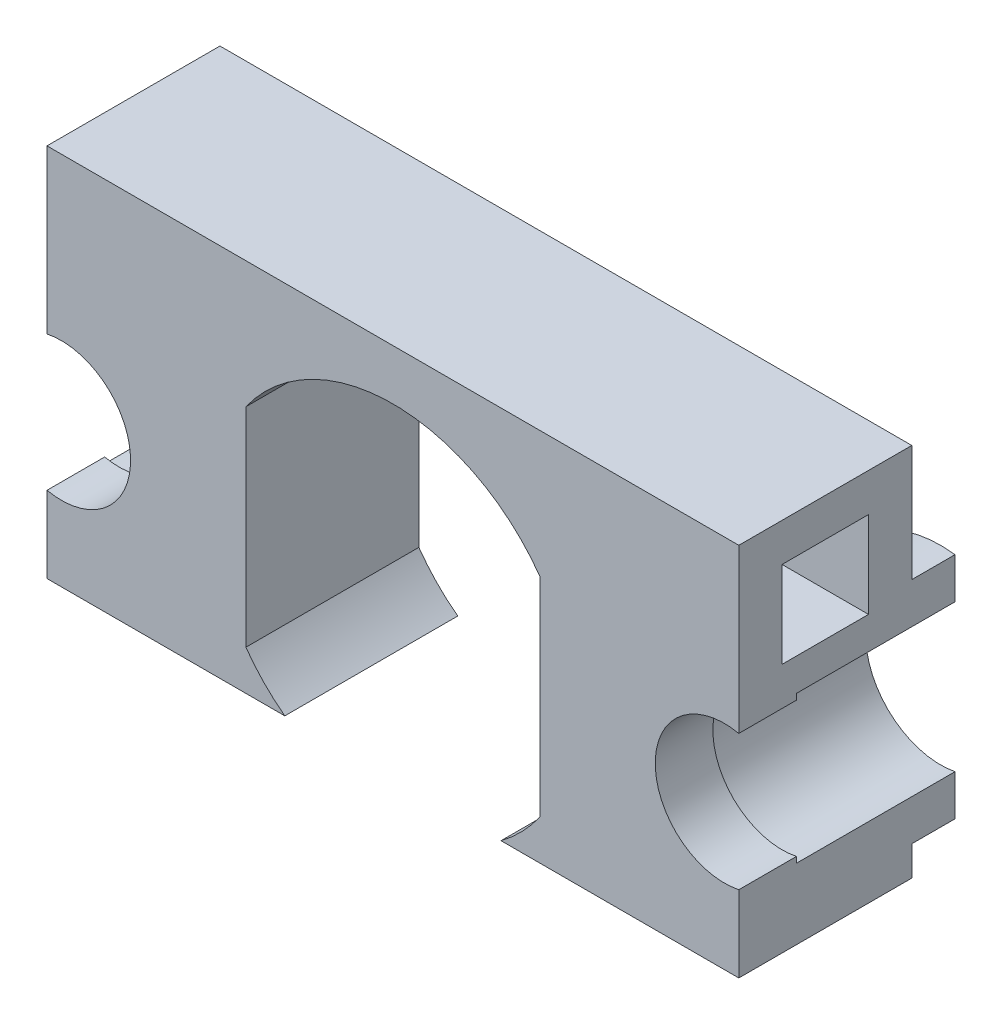
from build123d import *

# Parameters (mm, degrees)
SKETCH1_R            = 1
BOSS_EXTRUDE1_DEPTH  = 6
SKETCH2_R            = 2.6
CUT_EXTRUDE1_DEPTH   = 6
SKETCH3_W            = 7.6
SKETCH3_H            = 13
BOSS_EXTRUDE2_DEPTH  = 6
BOSS_EXTRUDE5_START  = -5
SKETCH6_W            = 3
SKETCH6_H            = 2
BOSS_EXTRUDE5_DEPTH  = 13
BOSS_EXTRUDE6_START  = -6
SKETCH10_R           = 4
SKETCH10_R_2         = 2.6
BOSS_EXTRUDE6_DEPTH  = 1.5
BOSS_EXTRUDE7_START  = -6
SKETCH12_R           = 2.6
SKETCH12_R_2         = 2.4
BOSS_EXTRUDE7_DEPTH  = 2
CUT_EXTRUDE2_DEPTH   = 7
SKETCH14_W           = 3
SKETCH14_H           = 6
CUT_EXTRUDE3_DEPTH   = 2
SKETCH15_W           = 0.2
SKETCH15_H           = 13
CUT_EXTRUDE5_DEPTH   = 7.5
SKETCH16_W           = 3
SKETCH16_H           = 3
CUT_EXTRUDE6_DEPTH   = 3
SKETCH17_W           = 2.8
SKETCH17_H           = 2.8
BOSS_EXTRUDE9_DEPTH  = 3
BOSS_EXTRUDE10_START = 24.4
SKETCH17_2_W         = 2.8
SKETCH17_2_H         = 2.8
BOSS_EXTRUDE10_DEPTH = 3
SKETCH18_W           = 5.7
SKETCH18_H           = 13
SKETCH18_W_2         = 13.3
CUT_EXTRUDE7_DEPTH   = 9
SKETCH19_W           = 3
SKETCH19_H           = 3
CUT_EXTRUDE8_DEPTH   = 3
CUT_EXTRUDE10_START  = -24
SKETCH19_3_W         = 3
SKETCH19_3_H         = 3
CUT_EXTRUDE10_DEPTH  = 3


with BuildPart() as part:
    # Sketch1 → Boss-Extrude1 (new body)
    with BuildSketch(Plane.XY):
        with BuildLine():
            ThreePointArc((3.75, -5), (4.47902769, -4.358991965), (5.1, -3.61282438))
            Line((5.1, -3.61282438), (5.1, 3.61282438))
            ThreePointArc((5.1, 3.61282438), (0, 6.25), (-5.1, 3.61282438))
            Line((-5.1, 3.61282438), (-5.1, -3.61282438))
            ThreePointArc((-5.1, -3.61282438), (-4.47902769, -4.358991965), (-3.75, -5))
            Line((-3.75, -5), (-14.7, -5))
            Line((-14.7, -5), (-14.7, 8))
            Line((-14.7, 8), (14.7, 8))
            Line((14.7, 8), (14.7, -5))
            Line((14.7, -5), (3.75, -5))
        make_face()
        with Locations((11.5, 0)):
            Circle(SKETCH1_R, mode=Mode.SUBTRACT)
        with Locations((-11.5, 0)):
            Circle(SKETCH1_R, mode=Mode.SUBTRACT)
    extrude(amount=BOSS_EXTRUDE1_DEPTH)

    # Sketch2 → Cut-Extrude1 (cut)
    with BuildSketch(Plane.XY):
        with Locations((-11.5, 0)):
            Circle(SKETCH2_R)
        with Locations((11.5, 0)):
            Circle(SKETCH2_R)
    extrude(amount=CUT_EXTRUDE1_DEPTH, mode=Mode.SUBTRACT)

    # Sketch3 → Boss-Extrude2 (add)
    with BuildSketch(Plane.XY):
        with Locations((-18.5, 1.5)):
            Rectangle(SKETCH3_W, SKETCH3_H)
    extrude(amount=BOSS_EXTRUDE2_DEPTH)

    # Sketch6 → Boss-Extrude5 (add)
    with BuildSketch(Plane(origin=(0, 0, 0), x_dir=(1, 0, 0), z_dir=(0, 1, 0)).offset(BOSS_EXTRUDE5_START)):
        with Locations((-23.8, -3)):
            Rectangle(SKETCH6_W, SKETCH6_H)
        with Locations((16.2, -3)):
            Rectangle(SKETCH6_W, SKETCH6_H)
    extrude(amount=BOSS_EXTRUDE5_DEPTH)

    # Sketch10 → Boss-Extrude6 (add)
    with BuildSketch(Plane.XY.offset(6).offset(BOSS_EXTRUDE6_START)):
        with Locations((-11.5, 0)):
            Circle(SKETCH10_R)
        with Locations((-11.5, 0)):
            Circle(SKETCH10_R_2, mode=Mode.SUBTRACT)
        with BuildLine():
            Line((14.7, 2.4), (14.7, -2.4))
            ThreePointArc((14.7, -2.4), (7.5, 0), (14.7, 2.4))
        make_face()
        with Locations((11.5, 0)):
            Circle(SKETCH10_R_2, mode=Mode.SUBTRACT)
    extrude(amount=-BOSS_EXTRUDE6_DEPTH)

    # Sketch12 → Boss-Extrude7 (add)
    with BuildSketch(Plane(origin=(0, 0, 0), x_dir=(-1, 0, 0), z_dir=(0, 0, -1)).offset(BOSS_EXTRUDE7_START)):
        with Locations((11.5, 0)):
            Circle(SKETCH12_R)
        with Locations((11.5, 0)):
            Circle(SKETCH12_R_2, mode=Mode.SUBTRACT)
        with Locations((-11.5, 0)):
            Circle(SKETCH12_R)
        with Locations((-11.5, 0)):
            Circle(SKETCH12_R_2, mode=Mode.SUBTRACT)
    extrude(amount=BOSS_EXTRUDE7_DEPTH)

    # Sketch13 → Cut-Extrude2 (cut)
    with BuildSketch(Plane.XZ.offset(5)):
        Polygon((-22.3, 0), (-16.3, 0), (-16.3, 2), (-17.8, 2), (-17.8, 6), (-20.8, 6), (-20.8, 2), (-22.3, 2), align=None)
    extrude(amount=-CUT_EXTRUDE2_DEPTH, mode=Mode.SUBTRACT)

    # Sketch14 → Cut-Extrude3 (cut)
    with BuildSketch(Plane(origin=(0, 0, 0), x_dir=(-1, 0, 0), z_dir=(0, 0, -1))):
        with Locations((19.3, 5)):
            Rectangle(SKETCH14_W, SKETCH14_H)
    extrude(amount=-CUT_EXTRUDE3_DEPTH, mode=Mode.SUBTRACT)

    # Sketch15 → Cut-Extrude5 (cut, symmetric)
    with BuildSketch(Plane.XY):
        with Locations((-12.1, 1.5)):
            Rectangle(SKETCH15_W, SKETCH15_H)
        with Locations((12.1, 1.5)):
            Rectangle(SKETCH15_W, SKETCH15_H)
    extrude(amount=CUT_EXTRUDE5_DEPTH, both=True, mode=Mode.SUBTRACT)

    # Sketch16 → Cut-Extrude6 (cut)
    with BuildSketch(Plane(origin=(12, 0, 0), x_dir=(0, 0, -1), z_dir=(1, 0, 0))):
        with Locations((-3, 5.173669459)):
            Rectangle(SKETCH16_W, SKETCH16_H)
    cut_extrude6 = extrude(amount=-CUT_EXTRUDE6_DEPTH, mode=Mode.SUBTRACT)

    # Mirror1: Cut-Extrude6 across plane
    add(cut_extrude6.mirror(Plane(origin=(0, 0, 0), x_dir=(0, 0, 1), z_dir=(1, 0, 0))), mode=Mode.SUBTRACT)

    # Sketch17 → Boss-Extrude9 (add)
    with BuildSketch(Plane(origin=(-12.2, 0, 0), x_dir=(0, 0, -1), z_dir=(1, 0, 0))):
        with Locations((-3, 5.173669459)):
            Rectangle(SKETCH17_W, SKETCH17_H)
    extrude(amount=BOSS_EXTRUDE9_DEPTH)

    # Sketch17_2 → Boss-Extrude10 (add)
    with BuildSketch(Plane(origin=(-12.2, 0, 0), x_dir=(0, 0, -1), z_dir=(1, 0, 0)).offset(BOSS_EXTRUDE10_START)):
        with Locations((-3, 5.173669459)):
            Rectangle(SKETCH17_2_W, SKETCH17_2_H)
    extrude(amount=-BOSS_EXTRUDE10_DEPTH)

    # Sketch18 → Cut-Extrude7 (cut, symmetric)
    with BuildSketch(Plane.XY):
        with Locations((14.85, 1.5)):
            Rectangle(SKETCH18_W, SKETCH18_H)
        with Locations((-18.65, 1.5)):
            Rectangle(SKETCH18_W_2, SKETCH18_H)
    extrude(amount=CUT_EXTRUDE7_DEPTH, both=True, mode=Mode.SUBTRACT)

    # Sketch19 → Cut-Extrude8 (cut)
    with BuildSketch(Plane(origin=(12, 0, 0), x_dir=(0, 0, -1), z_dir=(1, 0, 0))):
        with Locations((-3, 5.173669459)):
            Rectangle(SKETCH19_W, SKETCH19_H)
    extrude(amount=-CUT_EXTRUDE8_DEPTH, mode=Mode.SUBTRACT)

    # Sketch19_3 → Cut-Extrude10 (cut)
    with BuildSketch(Plane(origin=(12, 0, 0), x_dir=(0, 0, -1), z_dir=(1, 0, 0)).offset(CUT_EXTRUDE10_START)):
        with Locations((-3, 5.173669459)):
            Rectangle(SKETCH19_3_W, SKETCH19_3_H)
    extrude(amount=CUT_EXTRUDE10_DEPTH, mode=Mode.SUBTRACT)


solid = part.part
